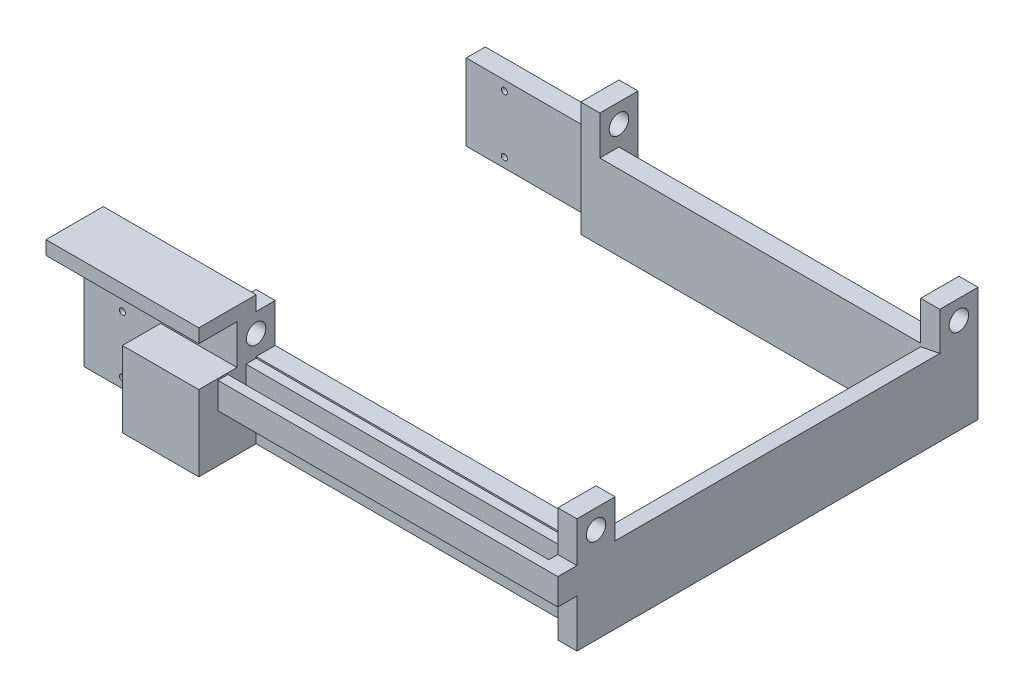
from build123d import *

# Parameters (mm, degrees)
BOSS_EXTRUDE1_DEPTH     = 25.4
CUT_EXTRUDE1_START      = -6.35
CUT_EXTRUDE1_DEPTH      = 107.95
SKETCH3_W               = 50.8
SKETCH3_H               = 25.4
BOSS_EXTRUDE2_DEPTH     = 6.35
BOSS_EXTRUDE3_START     = -120.65
SKETCH3_2_W             = 50.8
SKETCH3_2_H             = 25.4
BOSS_EXTRUDE3_DEPTH     = 6.35
BOSS_EXTRUDE4_START     = -25.4
SKETCH8_W               = 6.35
SKETCH8_H               = 12.7
BOSS_EXTRUDE4_DEPTH     = 38.1
SKETCH9_R               = 3.2385
CUT_EXTRUDE2_DEPTH      = 1
CUT_EXTRUDE2_DEPTH_BACK = 164.83
SKETCH10_R              = 1.000000032
CUT_EXTRUDE3_DEPTH      = 134.35
SKETCH11_W              = 25.4
SKETCH11_H              = 25.146
BOSS_EXTRUDE5_DEPTH     = 12.7
SKETCH13_W              = 44.45
SKETCH13_H              = 6.35
BOSS_EXTRUDE6_DEPTH     = 12.7
BOSS_EXTRUDE7_START     = -6.35
SKETCH15_W              = 50.8
SKETCH15_H              = 4.826
BOSS_EXTRUDE7_DEPTH     = 19.05
SKETCH17_W              = 50.8
SKETCH17_H              = 0.254
CUT_EXTRUDE4_DEPTH      = 12.7
SKETCH19_W              = 12.7
SKETCH19_H              = 8.763
BOSS_EXTRUDE8_DEPTH     = 113.03
SKETCH20_W              = 106.68
SKETCH20_H              = 0.254
CUT_EXTRUDE5_DEPTH      = 128
SKETCH22_W              = 106.68
SKETCH22_H              = 5.999999938
CUT_EXTRUDE6_DEPTH      = 25.638


with BuildPart() as part:
    # Sketch1 → Boss-Extrude1 (new body)
    with BuildSketch(Plane(origin=(0, 0, 0), x_dir=(1, 0, 0), z_dir=(0, 1, 0))):
        Polygon((3.175, 114.3), (0, 114.3), (0, 120.65), (119.38, 120.65), (119.38, 0), (0, 0), (0, 6.35), (3.175, 6.35), (113.03, 6.35), (113.03, 114.3), align=None)
    extrude(amount=BOSS_EXTRUDE1_DEPTH)

    # Sketch2 → Cut-Extrude1 (cut)
    with BuildSketch(Plane.XY.offset(CUT_EXTRUDE1_START)):
        Polygon((119.38, 25.4), (113.03, 24.13), (113.03, 25.4), align=None)
    extrude(amount=-CUT_EXTRUDE1_DEPTH, mode=Mode.SUBTRACT)

    # Sketch3 → Boss-Extrude2 (add)
    with BuildSketch(Plane.XY):
        with Locations((-19.05, 12.7)):
            Rectangle(SKETCH3_W, SKETCH3_H)
    extrude(amount=BOSS_EXTRUDE2_DEPTH)

    # Sketch3_2 → Boss-Extrude3 (add)
    with BuildSketch(Plane.XY.offset(BOSS_EXTRUDE3_START)):
        with Locations((-19.05, 12.7)):
            Rectangle(SKETCH3_2_W, SKETCH3_2_H)
    extrude(amount=-BOSS_EXTRUDE3_DEPTH)

    # Sketch8 → Boss-Extrude4 (add)
    with BuildSketch(Plane(origin=(0, 25.4, 0), x_dir=(1, 0, 0), z_dir=(0, 1, 0)).offset(BOSS_EXTRUDE4_START)):
        with Locations((116.205, 0)):
            Rectangle(SKETCH8_W, SKETCH8_H)
        with Locations((3.175, 0)):
            Rectangle(SKETCH8_W, SKETCH8_H)
        with Locations((3.175, 120.65)):
            Rectangle(SKETCH8_W, SKETCH8_H)
        with Locations((116.205, 120.65)):
            Rectangle(SKETCH8_W, SKETCH8_H)
    extrude(amount=BOSS_EXTRUDE4_DEPTH)

    # Sketch9 → Cut-Extrude2 (cut, two sides)
    with BuildSketch(Plane(origin=(119.38, 0, 0), x_dir=(0, 0, -1), z_dir=(1, 0, 0))) as cut_extrude2_sk:
        with Locations((0, 31.75)):
            Circle(SKETCH9_R)
        with Locations((120.65, 31.75)):
            Circle(SKETCH9_R)
    extrude(amount=CUT_EXTRUDE2_DEPTH, mode=Mode.SUBTRACT)
    extrude(cut_extrude2_sk.sketch, amount=-CUT_EXTRUDE2_DEPTH_BACK, mode=Mode.SUBTRACT)

    # Sketch10 → Cut-Extrude3 (cut, through all)
    with BuildSketch(Plane.XY.offset(6.35)):
        with Locations((-31.75, 22.225)):
            Circle(SKETCH10_R)
        with Locations((-31.75, 3.175)):
            Circle(SKETCH10_R)
    extrude(amount=-CUT_EXTRUDE3_DEPTH, mode=Mode.SUBTRACT)

    # Sketch11 → Boss-Extrude5 (add)
    with BuildSketch(Plane.XY.offset(6.35)):
        with Locations((-6.35, 12.573)):
            Rectangle(SKETCH11_W, SKETCH11_H)
    extrude(amount=BOSS_EXTRUDE5_DEPTH)

    # Sketch13 → Boss-Extrude6 (add)
    with BuildSketch(Plane(origin=(0, 25.4, 0), x_dir=(1, 0, 0), z_dir=(0, 1, 0))):
        with Locations((-22.225, -3.175)):
            Rectangle(SKETCH13_W, SKETCH13_H)
    extrude(amount=BOSS_EXTRUDE6_DEPTH)

    # Sketch15 → Boss-Extrude7 (add)
    with BuildSketch(Plane.XY.offset(6.35).offset(BOSS_EXTRUDE7_START)):
        with Locations((-19.05, 40.513)):
            Rectangle(SKETCH15_W, SKETCH15_H)
    extrude(amount=BOSS_EXTRUDE7_DEPTH)

    # Sketch17 → Cut-Extrude4 (cut)
    with BuildSketch(Plane.XY.offset(19.05)):
        with Locations((-19.05, 38.227)):
            Rectangle(SKETCH17_W, SKETCH17_H)
    extrude(amount=-CUT_EXTRUDE4_DEPTH, mode=Mode.SUBTRACT)

    # Sketch19 → Boss-Extrude8 (add)
    with BuildSketch(Plane(origin=(6.35, 0, 0), x_dir=(0, 0, -1), z_dir=(1, 0, 0))):
        with Locations((-6.35, 20.2565)):
            Rectangle(SKETCH19_W, SKETCH19_H)
    extrude(amount=BOSS_EXTRUDE8_DEPTH)

    # Sketch20 → Cut-Extrude5 (cut, through all)
    with BuildSketch(Plane.XY):
        with Locations((59.69, 25.273)):
            Rectangle(SKETCH20_W, SKETCH20_H)
    extrude(amount=-CUT_EXTRUDE5_DEPTH, mode=Mode.SUBTRACT)

    # Sketch22 → Cut-Extrude6 (cut, through all)
    with BuildSketch(Plane(origin=(0, 24.638, 0), x_dir=(1, 0, 0), z_dir=(0, 1, 0))):
        with Locations((59.69, -6.35)):
            Rectangle(SKETCH22_W, SKETCH22_H)
    extrude(amount=-CUT_EXTRUDE6_DEPTH, mode=Mode.SUBTRACT)


solid = part.part
